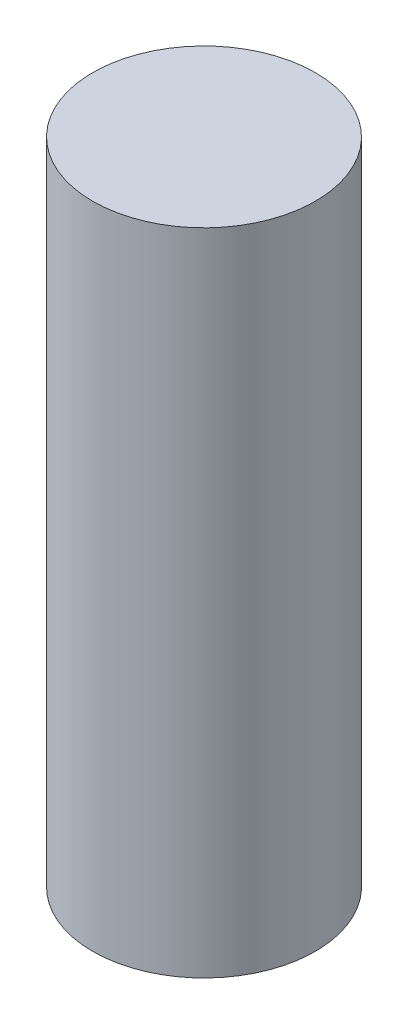
from build123d import *

# Parameters (mm, degrees)
SKETCH1_R           = 6
BOSS_EXTRUDE1_DEPTH = 35


with BuildPart() as part:
    # Sketch1 → Boss-Extrude1 (new body)
    with BuildSketch(Plane(origin=(0, 0, 0), x_dir=(1, 0, 0), z_dir=(0, 1, 0))):
        Circle(SKETCH1_R)
    extrude(amount=BOSS_EXTRUDE1_DEPTH)


solid = part.part
